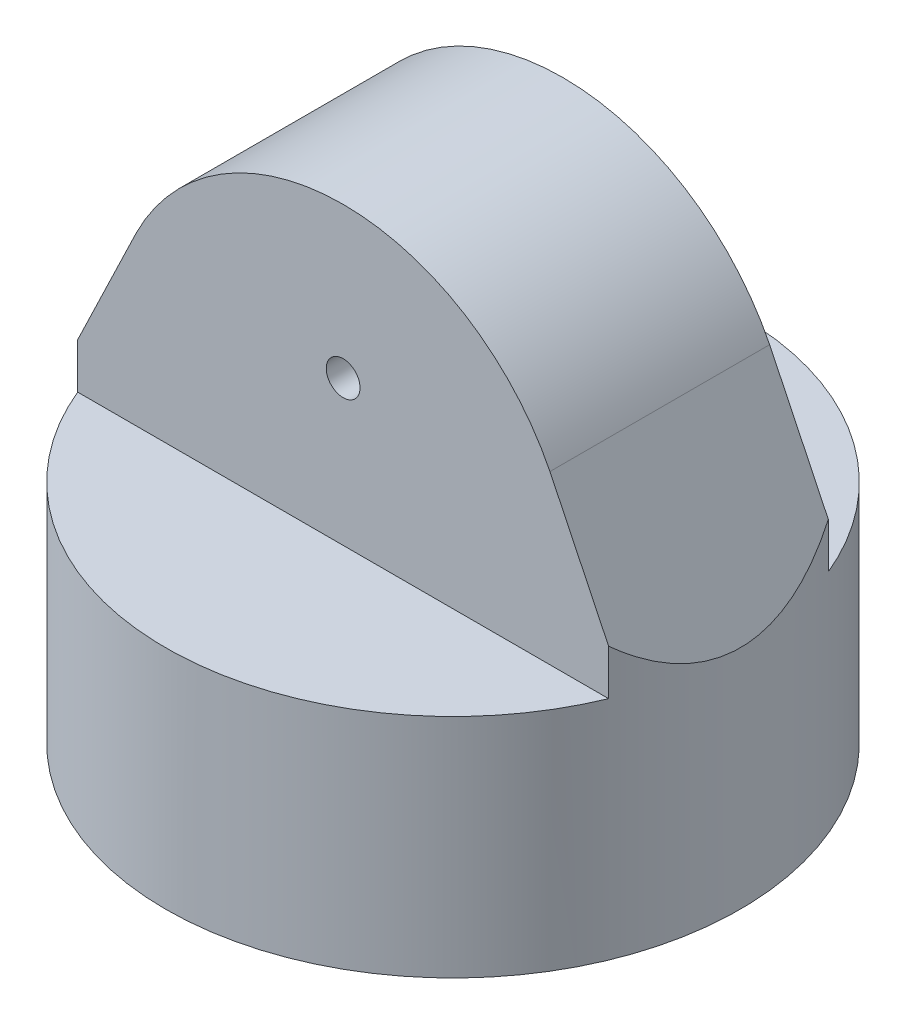
from build123d import *

# Parameters (mm, degrees)
SKETCH1_R           = 85
SKETCH1_R_2         = 75
BOSS_EXTRUDE1_DEPTH = 35
SKETCH2_R           = 85
BOSS_EXTRUDE2_DEPTH = 4
SKETCH3_R           = 5
BOSS_EXTRUDE3_DEPTH = 32.5
SKETCH4_R           = 95.738737625
SKETCH4_R_2         = 85
CUT_EXTRUDE1_DEPTH  = 67
CUT_EXTRUDE2_DEPTH  = 58
SKETCH6_R           = 85
SKETCH6_R_2         = 75
BOSS_EXTRUDE4_DEPTH = 28


with BuildPart() as part:
    # Sketch1 → Boss-Extrude1 (new body)
    with BuildSketch(Plane(origin=(0, 0, 0), x_dir=(1, 0, 0), z_dir=(0, 1, 0))):
        Circle(SKETCH1_R)
        Circle(SKETCH1_R_2, mode=Mode.SUBTRACT)
    extrude(amount=BOSS_EXTRUDE1_DEPTH)

    # Sketch2 → Boss-Extrude2 (add)
    with BuildSketch(Plane(origin=(0, 35, 0), x_dir=(1, 0, 0), z_dir=(0, 1, 0))):
        Circle(SKETCH2_R)
    extrude(amount=BOSS_EXTRUDE2_DEPTH)

    # Sketch3 → Boss-Extrude3 (add, symmetric)
    with BuildSketch(Plane.XY):
        with BuildLine():
            Line((-85, 39), (-61.181000395, 88.51271152))
            ThreePointArc((-61.181000395, 88.51271152), (0, 126.386849251), (61.181000395, 88.51271152))
            Line((61.181000395, 88.51271152), (85, 39))
            Line((85, 39), (-85, 39))
        make_face()
        with Locations((0, 81.844221237)):
            Circle(SKETCH3_R, mode=Mode.SUBTRACT)
    extrude(amount=BOSS_EXTRUDE3_DEPTH, both=True)

    # Sketch4 → Cut-Extrude1 (cut)
    with BuildSketch(Plane(origin=(0, 39, 0), x_dir=(1, 0, 0), z_dir=(0, 1, 0))):
        Circle(SKETCH4_R)
        Circle(SKETCH4_R_2, mode=Mode.SUBTRACT)
    extrude(amount=CUT_EXTRUDE1_DEPTH, mode=Mode.SUBTRACT)

    # Sketch5 → Cut-Extrude2 (cut)
    with BuildSketch(Plane.XZ.offset(-35)):
        with BuildLine():
            Line((-15.1, -17.6), (15.1, -17.6))
            ThreePointArc((15.1, -17.6), (16.867766953, -16.867766953), (17.6, -15.1))
            Line((17.6, -15.1), (17.6, 15.1))
            ThreePointArc((17.6, 15.1), (16.867766953, 16.867766953), (15.1, 17.6))
            Line((15.1, 17.6), (-15.1, 17.6))
            ThreePointArc((-15.1, 17.6), (-16.867766953, 16.867766953), (-17.6, 15.1))
            Line((-17.6, 15.1), (-17.6, -15.1))
            ThreePointArc((-17.6, -15.1), (-16.867766953, -16.867766953), (-15.1, -17.6))
        make_face()
    extrude(amount=-CUT_EXTRUDE2_DEPTH, mode=Mode.SUBTRACT)

    # Sketch6 → Boss-Extrude4 (add)
    with BuildSketch(Plane.XZ):
        Circle(SKETCH6_R)
        Circle(SKETCH6_R_2, mode=Mode.SUBTRACT)
    extrude(amount=BOSS_EXTRUDE4_DEPTH)


solid = part.part
